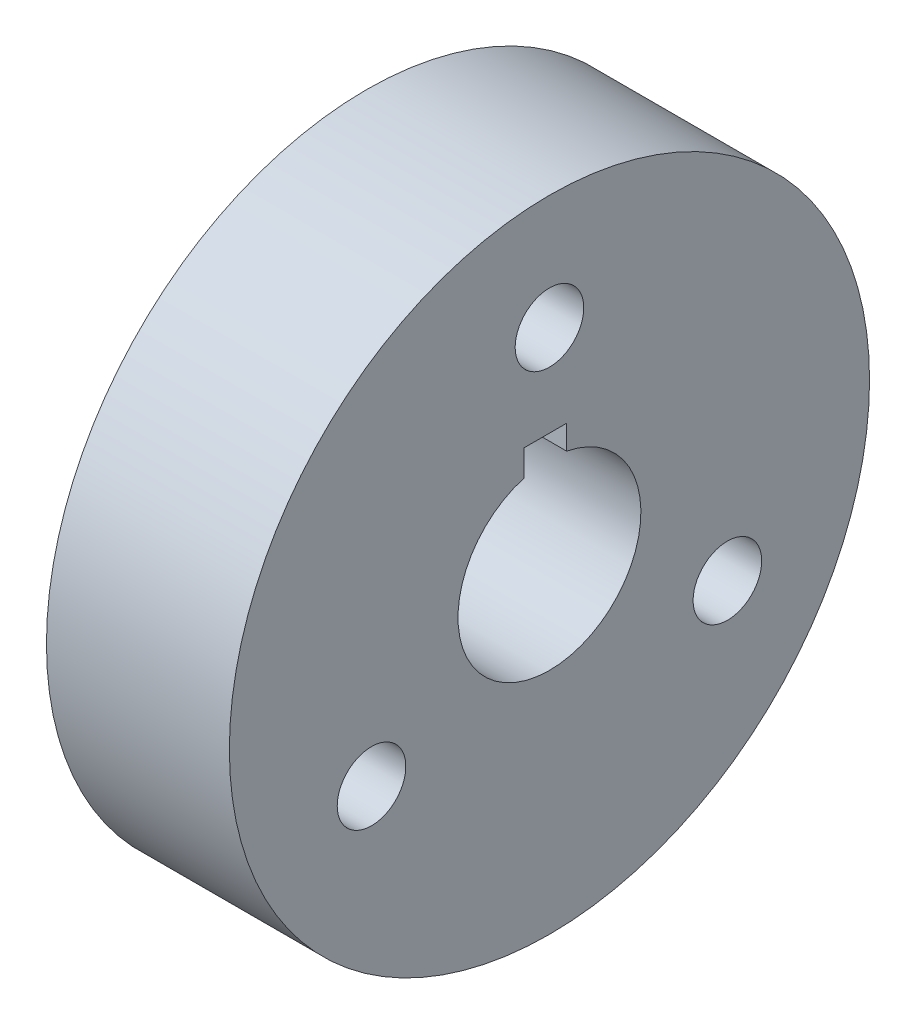
from build123d import *

# Parameters (mm, degrees)
CUT_EXTRUDE1_DEPTH = 61
SKETCH3_R          = 7.5
CUT_EXTRUDE2_DEPTH = 21
CIRPATTERN1_COUNT  = 3


with BuildPart() as part:
    # Sketch1 → Revolve1 (revolve)
    with BuildSketch(Plane.XY):
        Polygon((-22.523252325, 13.422459893), (-22.523252325, -16.577540107), (37.476747675, -16.577540107), (37.476747675, 53.422459893), (-2.523252325, 53.422459893), (-2.523252325, 43.422459893), (17.476747675, 43.422459893), (17.476747675, 13.422459893), align=None)
    revolve(axis=Axis((-22.523252325, -16.577540107, 0), (1, 0, 0)))

    # Sketch2 → Cut-Extrude1 (cut, through all)
    with BuildSketch(Plane.ZY.offset(22.523252325)):
        with BuildLine():
            Line((-3.763166571, 3.06523407), (-3.763166571, 8.354397525))
            Line((-3.763166571, 8.354397525), (5.575592602, 8.354397525))
            Line((5.575592602, 8.354397525), (5.575592602, 2.62956189))
            ThreePointArc((5.575592602, 2.62956189), (-0.932027141, -36.555811439), (-3.763166571, 3.06523407))
        make_face()
    extrude(amount=-CUT_EXTRUDE1_DEPTH, mode=Mode.SUBTRACT)

    # Sketch3 → Cut-Extrude2 (cut, through all)
    with BuildSketch(Plane.ZY.offset(-17.476747675)):
        with Locations((0, 28.354397525)):
            Circle(SKETCH3_R)
    cut_extrude2 = extrude(amount=-CUT_EXTRUDE2_DEPTH, mode=Mode.SUBTRACT)

    # CirPattern1: Cut-Extrude2 ×3 about axis
    cirpattern1_axis = Axis((0, -16.577540107, 0), (1, 0, 0))
    for i in range(1, CIRPATTERN1_COUNT):
        add(cut_extrude2.rotate(cirpattern1_axis, i * 360 / CIRPATTERN1_COUNT), mode=Mode.SUBTRACT)


solid = part.part
